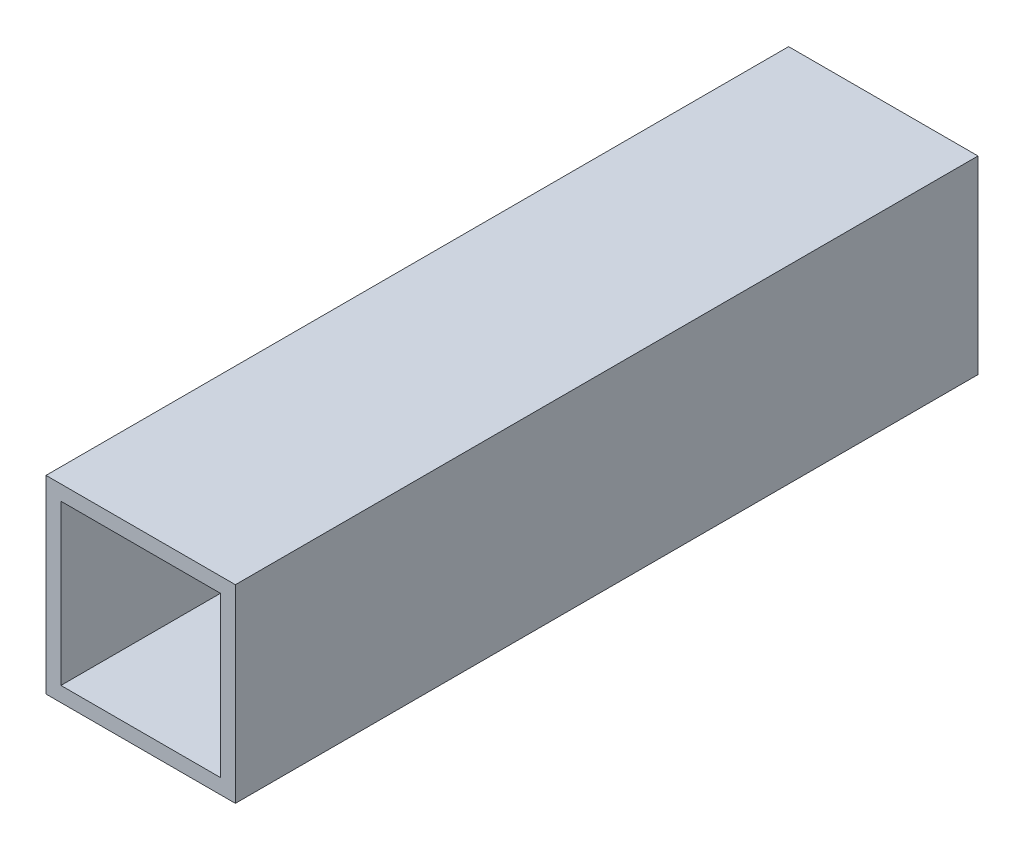
from build123d import *

# Parameters (mm, degrees)
SKETCH1_W           = 25.4
SKETCH1_H           = 25.4
SKETCH1_W_2         = 21.4
SKETCH1_H_2         = 21.4
BOSS_EXTRUDE1_DEPTH = 99.6


with BuildPart() as part:
    # Sketch1 → Boss-Extrude1 (new body)
    with BuildSketch(Plane.XY):
        Rectangle(SKETCH1_W, SKETCH1_H)
        Rectangle(SKETCH1_W_2, SKETCH1_H_2, mode=Mode.SUBTRACT)
    extrude(amount=BOSS_EXTRUDE1_DEPTH)


solid = part.part
